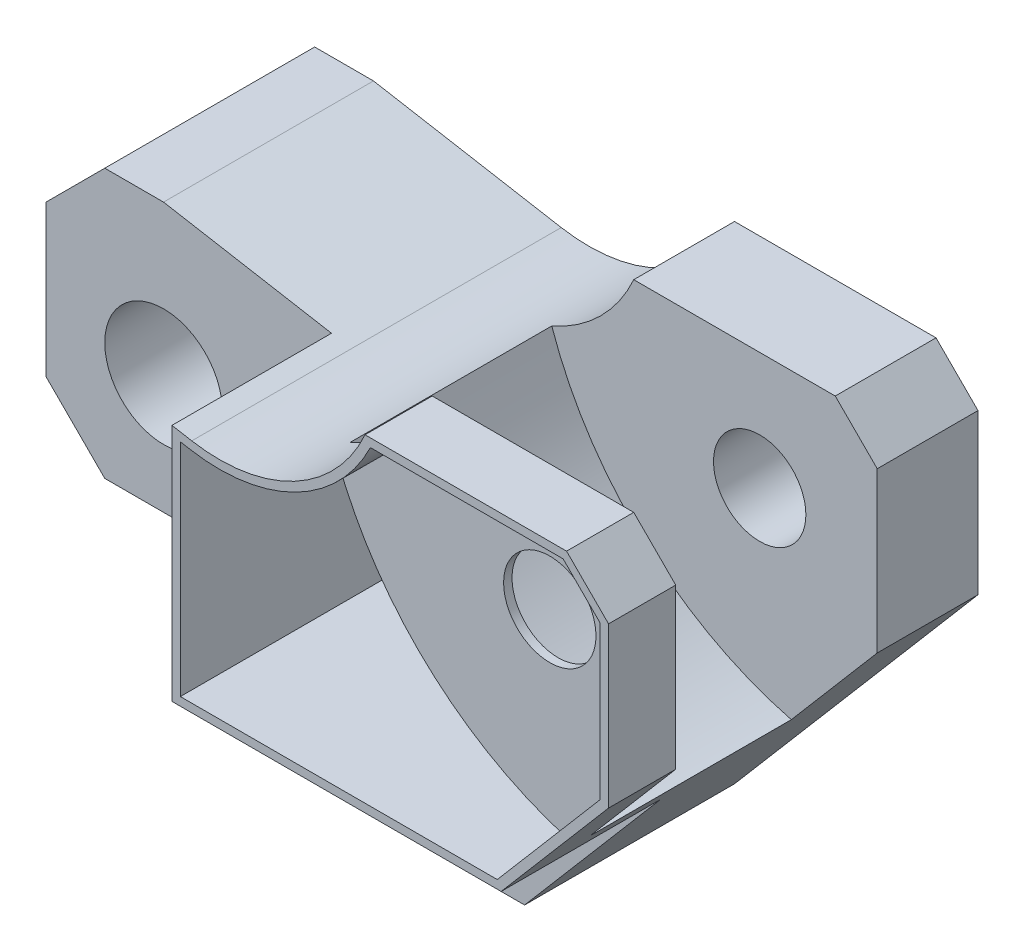
from build123d import *

# Parameters (mm, degrees)
SKETCH1_R               = 7
BOSS_EXTRUDE1_DEPTH     = 44
SKETCH1_2_R             = 7
BOSS_EXTRUDE2_DEPTH     = 44
CUT_EXTRUDE1_DEPTH      = 1
CUT_EXTRUDE1_DEPTH_BACK = 19
SKETCH4_W               = 50.710370583
SKETCH4_H               = 19
CUT_EXTRUDE2_DEPTH      = 52
SKETCH5_R               = 5.5
CUT_EXTRUDE3_DEPTH      = 45
CUT_EXTRUDE4_DEPTH      = 24
CUT_EXTRUDE12_DEPTH     = 7
CUT_EXTRUDE13_DEPTH     = 25


with BuildPart() as part:
    # Sketch1 → Boss-Extrude1 (new body)
    with BuildSketch(Plane.XY):
        with BuildLine():
            Line((-7, -14), (25.575538911, -14))
            ThreePointArc((25.575538911, -14), (28.840774692, -15.213413768), (30.521177653, -18.264705882))
            ThreePointArc((30.521177653, -18.264705882), (32.858007856, -26.115672061), (37.296980053, -33))
            Line((37.296980053, -33), (43, -33))
            Line((43, -33), (72, 1))
            Line((72, 1), (72, 20))
            Line((72, 20), (67, 25))
            Line((67, 25), (43, 25))
            ThreePointArc((43, 25), (34.561098706, 15.982044142), (22.361380836, 14.057085233))
            Line((22.361380836, 14.057085233), (0, 18))
            Line((0, 18), (-7, 18))
            Line((-7, 18), (-14, 11))
            Line((-14, 11), (-14, -7))
            Line((-14, -7), (-7, -14))
        make_face()
        Circle(SKETCH1_R, mode=Mode.SUBTRACT)
    extrude(amount=BOSS_EXTRUDE1_DEPTH)

    # Sketch1_2 → Boss-Extrude2 (add)
    with BuildSketch(Plane.XY):
        with BuildLine():
            Line((-7, -14), (25.575538911, -14))
            ThreePointArc((25.575538911, -14), (28.840774692, -15.213413768), (30.521177653, -18.264705882))
            ThreePointArc((30.521177653, -18.264705882), (32.858007856, -26.115672061), (37.296980053, -33))
            Line((37.296980053, -33), (43, -33))
            Line((43, -33), (72, 1))
            Line((72, 1), (72, 20))
            Line((72, 20), (67, 25))
            Line((67, 25), (43, 25))
            ThreePointArc((43, 25), (34.561098706, 15.982044142), (22.361380836, 14.057085233))
            Line((22.361380836, 14.057085233), (0, 18))
            Line((0, 18), (-7, 18))
            Line((-7, 18), (-14, 11))
            Line((-14, 11), (-14, -7))
            Line((-14, -7), (-7, -14))
        make_face()
        Circle(SKETCH1_2_R, mode=Mode.SUBTRACT)
    extrude(amount=BOSS_EXTRUDE2_DEPTH)

    # Sketch3 → Cut-Extrude1 (cut, two sides)
    with BuildSketch(Plane.XY.offset(44)) as cut_extrude1_sk:
        Polygon((-150.317212119, -14), (25.575538911, -14), (59.205882353, -14), (235.098633383, -14), (235.098633383, -365.78550206), (-150.317212119, -365.78550206), align=None)
    extrude(amount=CUT_EXTRUDE1_DEPTH, mode=Mode.SUBTRACT)
    extrude(cut_extrude1_sk.sketch, amount=-CUT_EXTRUDE1_DEPTH_BACK, mode=Mode.SUBTRACT)

    # Sketch4 → Cut-Extrude2 (cut, through all)
    with BuildSketch(Plane(origin=(0, 18, 0), x_dir=(1, 0, 0), z_dir=(0, 1, 0))):
        with Locations((-5.355185292, -34.5)):
            Rectangle(SKETCH4_W, SKETCH4_H)
    extrude(amount=-CUT_EXTRUDE2_DEPTH, mode=Mode.SUBTRACT)

    # Sketch5 → Cut-Extrude3 (cut, through all)
    with BuildSketch(Plane.XY.offset(44)):
        with Locations((58, 11)):
            Circle(SKETCH5_R)
    extrude(amount=-CUT_EXTRUDE3_DEPTH, mode=Mode.SUBTRACT)

    # Sketch9 → Cut-Extrude4 (cut)
    with BuildSketch(Plane(origin=(0, 0, 12), x_dir=(-1, 0, 0), z_dir=(0, 0, -1))):
        with BuildLine():
            Line((-72, 20), (-67, 25))
            Line((-67, 25), (-43, 25))
            ThreePointArc((-43, 25), (-39.021244343, 19.259333621), (-33.236936549, 15.344294617))
            ThreePointArc((-33.236936549, 15.344294617), (-44.184262982, -1.419294771), (-61.764705882, -11))
            Line((-61.764705882, -11), (-72, 1))
            Line((-72, 1), (-72, 20))
        make_face()
    extrude(amount=-CUT_EXTRUDE4_DEPTH, mode=Mode.SUBTRACT)

    # Sketch16 → Cut-Extrude12 (cut)
    with BuildSketch(Plane.XY.offset(44)):
        with BuildLine():
            Line((21, 13.281706793), (21, -13))
            Line((21, -13), (58.744476296, -13))
            Line((58.744476296, -13), (71, 1.368545033))
            Line((71, 1.368545033), (71, 19.585786438))
            Line((71, 19.585786438), (66.585786438, 24))
            Line((66.585786438, 24), (43.636084685, 24))
            ThreePointArc((43.636084685, 24), (34.740005768, 14.948047079), (22.187732658, 13.07227748))
            Line((22.187732658, 13.07227748), (21, 13.281706793))
        make_face()
    extrude(amount=-CUT_EXTRUDE12_DEPTH, mode=Mode.SUBTRACT)

    # Sketch17 → Cut-Extrude13 (cut)
    with BuildSketch(Plane.XY.offset(37)):
        with BuildLine():
            Line((58.744476296, -13), (59.986847747, -11.543426575))
            ThreePointArc((59.986847747, -11.543426575), (43.310181683, -1.972127362), (32.646682943, 14.028208705))
            ThreePointArc((32.646682943, 14.028208705), (27.481076416, 12.851449437), (22.187732658, 13.07227748))
            Line((22.187732658, 13.07227748), (21, 13.281706793))
            Line((21, 13.281706793), (21, -13))
            Line((21, -13), (58.744476296, -13))
        make_face()
    extrude(amount=-CUT_EXTRUDE13_DEPTH, mode=Mode.SUBTRACT)


solid = part.part
